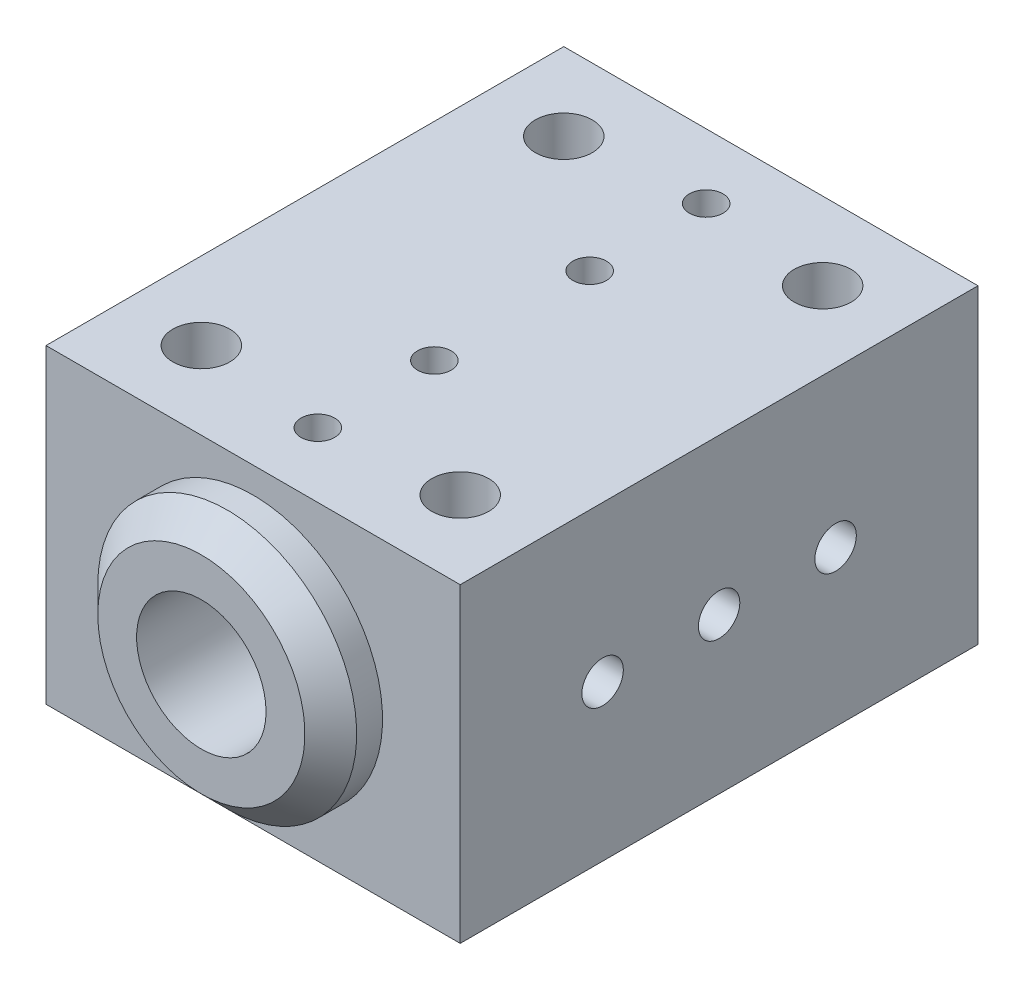
from build123d import *

# Parameters (mm, degrees)
BASE_SKETCH_W                   = 16
BASE_SKETCH_H                   = 20
BASE_EXTRUDE_DEPTH              = 12
TOP_START                       = 10
PROTRUSION_SKETCH_R             = 5
TOP_PROTRUSION_EXTRUDE_DEPTH    = 2
BOTTOM_START                    = -10
PROTRUSION_SKETCH_2_R           = 5
BOTTOM_PROTRUSION_EXTRUDE_DEPTH = 2
PROTRUSION_CHAMFER_SIZE         = 1
F_5_0MM_DOWEL_HOLE1_D           = 5
F_1_6MM_DOWEL_HOLE1_D           = 1.6
F_1_6MM_DOWEL_HOLE1_DEPTH       = 8
F_1_6MM_DOWEL_HOLE1_TIP         = 0.480688495
F_1_6_1_6_DIAMETER_HOLE4_D      = 1.6
F_1_6_1_6_DIAMETER_HOLE4_DEPTH  = 3.5
F_1_6_1_6_DIAMETER_HOLE4_TIP    = 0.480688495
M2X0_4_TAPPED_HOLE1_D           = 1.6
M2X0_4_TAPPED_HOLE1_DEPTH       = 4
M2X0_4_TAPPED_HOLE1_TIP         = 0.480688495
M2X0_4_TAPPED_HOLE2_D           = 1.6
M2X0_4_TAPPED_HOLE2_DEPTH       = 4
M2X0_4_TAPPED_HOLE2_TIP         = 0.480688495
F_2_2_2_2_DIAMETER_HOLE1_D      = 2.2
F_1_3_1_3_DIAMETER_HOLE1_D      = 1.3
F_1_3_1_3_DIAMETER_HOLE1_DEPTH  = 6
F_1_3_1_3_DIAMETER_HOLE1_TIP    = 0.390559402
F_1_3_1_3_DIAMETER_HOLE2_D      = 1.3
F_1_3_1_3_DIAMETER_HOLE2_DEPTH  = 6
F_1_3_1_3_DIAMETER_HOLE2_TIP    = 0.390559402
F_1_3_1_3_DIAMETER_HOLE3_D      = 1.3
F_1_3_1_3_DIAMETER_HOLE3_DEPTH  = 6
F_1_3_1_3_DIAMETER_HOLE3_TIP    = 0.390559402


with BuildPart() as part:
    # Base Sketch → Base Extrude (new body)
    with BuildSketch(Plane(origin=(0, 0, 0), x_dir=(1, 0, 0), z_dir=(0, 1, 0))):
        Rectangle(BASE_SKETCH_W, BASE_SKETCH_H)
    extrude(amount=BASE_EXTRUDE_DEPTH)

    # Protrusion Sketch → Top Protrusion Extrude (add)
    with BuildSketch(Plane.XY.offset(TOP_START)):
        with Locations((0, 6)):
            Circle(PROTRUSION_SKETCH_R)
    extrude(amount=TOP_PROTRUSION_EXTRUDE_DEPTH)

    # Protrusion Sketch_2 → Bottom Protrusion Extrude (add)
    with BuildSketch(Plane.XY.offset(BOTTOM_START)):
        with Locations((0, 6)):
            Circle(PROTRUSION_SKETCH_2_R)
    extrude(amount=-BOTTOM_PROTRUSION_EXTRUDE_DEPTH)

    # Protrusion Chamfer
    protrusion_chamfer_edges = [part.edges().sort_by_distance(p)[0] for p in [
        (-5, 6, 12),
        (-5, 6, -12),
    ]]
    chamfer(protrusion_chamfer_edges, length=PROTRUSION_CHAMFER_SIZE)

    # Ø5.0mm Dowel Hole1 (through all)
    with Locations(Plane.XY.offset(12)):
        with Locations((0, 6)):
            Hole(F_5_0MM_DOWEL_HOLE1_D / 2)

    # Ø1.6mm Dowel Hole1
    with Locations(Plane(origin=(8, 0, 0), x_dir=(0, 0, -1), z_dir=(1, 0, 0))):
        with Locations((0, 6)):
            Hole(F_1_6MM_DOWEL_HOLE1_D / 2, depth=F_1_6MM_DOWEL_HOLE1_DEPTH)
            with Locations((0, 0, -(F_1_6MM_DOWEL_HOLE1_DEPTH + F_1_6MM_DOWEL_HOLE1_TIP / 2))):  # 118° drill point
                Cone(0, F_1_6MM_DOWEL_HOLE1_D / 2, F_1_6MM_DOWEL_HOLE1_TIP, mode=Mode.SUBTRACT)

    # Ø1.6 (1.6) Diameter Hole4
    with Locations(Plane.ZY.offset(8)):
        with Locations((0, 6)):
            Hole(F_1_6_1_6_DIAMETER_HOLE4_D / 2, depth=F_1_6_1_6_DIAMETER_HOLE4_DEPTH)
            with Locations((0, 0, -(F_1_6_1_6_DIAMETER_HOLE4_DEPTH + F_1_6_1_6_DIAMETER_HOLE4_TIP / 2))):  # 118° drill point
                Cone(0, F_1_6_1_6_DIAMETER_HOLE4_D / 2, F_1_6_1_6_DIAMETER_HOLE4_TIP, mode=Mode.SUBTRACT)

    # M2x0.4 Tapped Hole1
    with Locations(Plane(origin=(8, 0, 0), x_dir=(0, 0, -1), z_dir=(1, 0, 0))):
        with Locations((-4.5, 6), (4.5, 6)):
            Hole(M2X0_4_TAPPED_HOLE1_D / 2, depth=M2X0_4_TAPPED_HOLE1_DEPTH)
            with Locations((0, 0, -(M2X0_4_TAPPED_HOLE1_DEPTH + M2X0_4_TAPPED_HOLE1_TIP / 2))):  # 118° drill point
                Cone(0, M2X0_4_TAPPED_HOLE1_D / 2, M2X0_4_TAPPED_HOLE1_TIP, mode=Mode.SUBTRACT)

    # M2x0.4 Tapped Hole2
    with Locations(Plane.ZY.offset(8)):
        with Locations((-4.5, 6), (4.5, 6)):
            Hole(M2X0_4_TAPPED_HOLE2_D / 2, depth=M2X0_4_TAPPED_HOLE2_DEPTH)
            with Locations((0, 0, -(M2X0_4_TAPPED_HOLE2_DEPTH + M2X0_4_TAPPED_HOLE2_TIP / 2))):  # 118° drill point
                Cone(0, M2X0_4_TAPPED_HOLE2_D / 2, M2X0_4_TAPPED_HOLE2_TIP, mode=Mode.SUBTRACT)

    # Ø2.2 (2.2) Diameter Hole1 (through all)
    with Locations(Plane(origin=(0, 12, 0), x_dir=(1, 0, 0), z_dir=(0, 1, 0))):
        with Locations((-5, 7), (5, 7), (-5, -7), (5, -7)):
            Hole(F_2_2_2_2_DIAMETER_HOLE1_D / 2)

    # Ø1.3 (1.3) Diameter Hole1
    with Locations(Plane(origin=(0, 0, 0), x_dir=(-1, 0, 0), z_dir=(0, -1, 0))):
        with Locations((0, 7.5), (0, -7.5)):
            Hole(F_1_3_1_3_DIAMETER_HOLE1_D / 2, depth=F_1_3_1_3_DIAMETER_HOLE1_DEPTH)
            with Locations((0, 0, -(F_1_3_1_3_DIAMETER_HOLE1_DEPTH + F_1_3_1_3_DIAMETER_HOLE1_TIP / 2))):  # 118° drill point
                Cone(0, F_1_3_1_3_DIAMETER_HOLE1_D / 2, F_1_3_1_3_DIAMETER_HOLE1_TIP, mode=Mode.SUBTRACT)

    # Ø1.3 (1.3) Diameter Hole2
    with Locations(Plane(origin=(0, 0, 0), x_dir=(-1, 0, 0), z_dir=(0, -1, 0))):
        with Locations((5, 0)):
            Hole(F_1_3_1_3_DIAMETER_HOLE2_D / 2, depth=F_1_3_1_3_DIAMETER_HOLE2_DEPTH)
            with Locations((0, 0, -(F_1_3_1_3_DIAMETER_HOLE2_DEPTH + F_1_3_1_3_DIAMETER_HOLE2_TIP / 2))):  # 118° drill point
                Cone(0, F_1_3_1_3_DIAMETER_HOLE2_D / 2, F_1_3_1_3_DIAMETER_HOLE2_TIP, mode=Mode.SUBTRACT)

    # Ø1.3 (1.3) Diameter Hole3
    with Locations(Plane(origin=(0, 12, 0), x_dir=(1, 0, 0), z_dir=(0, 1, 0))):
        with Locations((0, -7.5), (0, -3), (0, 3), (0, 7.5)):
            Hole(F_1_3_1_3_DIAMETER_HOLE3_D / 2, depth=F_1_3_1_3_DIAMETER_HOLE3_DEPTH)
            with Locations((0, 0, -(F_1_3_1_3_DIAMETER_HOLE3_DEPTH + F_1_3_1_3_DIAMETER_HOLE3_TIP / 2))):  # 118° drill point
                Cone(0, F_1_3_1_3_DIAMETER_HOLE3_D / 2, F_1_3_1_3_DIAMETER_HOLE3_TIP, mode=Mode.SUBTRACT)


solid = part.part
